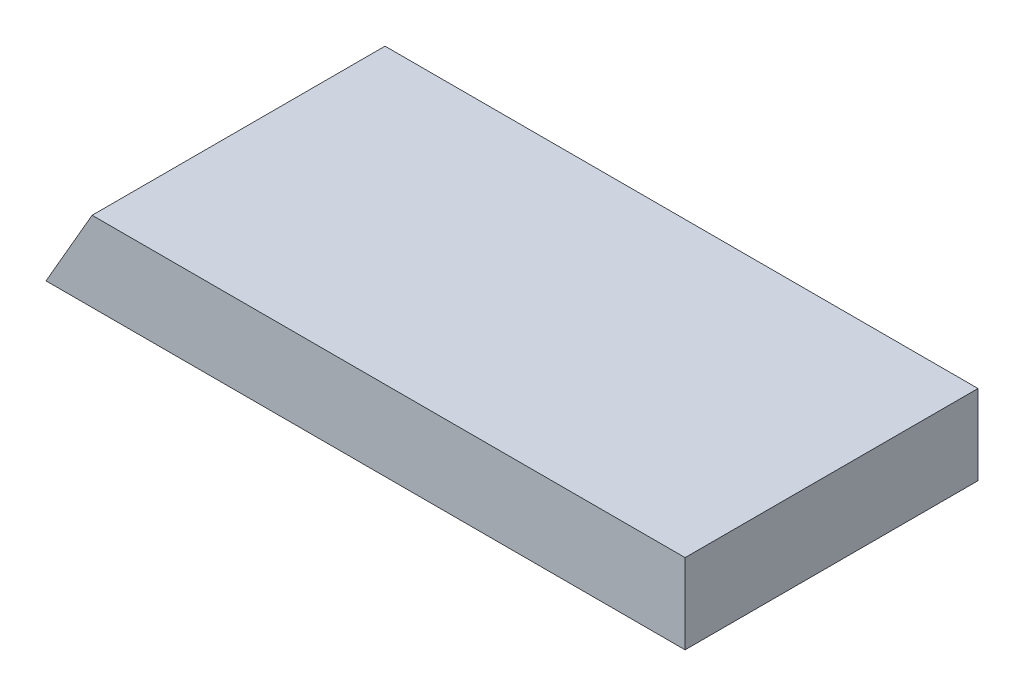
from build123d import *

# Parameters (mm, degrees)
SKETCH1_W               = 304.8
SKETCH1_H               = 139.7
BOSS_EXTRUDE1_DEPTH     = 38.1
CUT_EXTRUDE1_DEPTH      = 1
CUT_EXTRUDE1_DEPTH_BACK = 140.7


with BuildPart() as part:
    # Sketch1 → Boss-Extrude1 (new body)
    with BuildSketch(Plane(origin=(0, 0, 0), x_dir=(1, 0, 0), z_dir=(0, 1, 0))):
        with Locations((153.967323935, 69.85)):
            Rectangle(SKETCH1_W, SKETCH1_H)
    extrude(amount=BOSS_EXTRUDE1_DEPTH)

    # Sketch2 → Cut-Extrude1 (cut, two sides)
    with BuildSketch(Plane(origin=(0, 0, -139.7), x_dir=(-1, 0, 0), z_dir=(0, 0, -1))) as cut_extrude1_sk:
        Polygon((310.604696275, -540.697799705), (-1.567323935, 0), (-23.564369192, 38.1), (-335.736389402, 578.797799705), (745.659210009, 1203.141840126), (1392.000295686, 83.646240715), align=None)
    extrude(amount=CUT_EXTRUDE1_DEPTH, mode=Mode.SUBTRACT)
    extrude(cut_extrude1_sk.sketch, amount=-CUT_EXTRUDE1_DEPTH_BACK, mode=Mode.SUBTRACT)


solid = part.part
